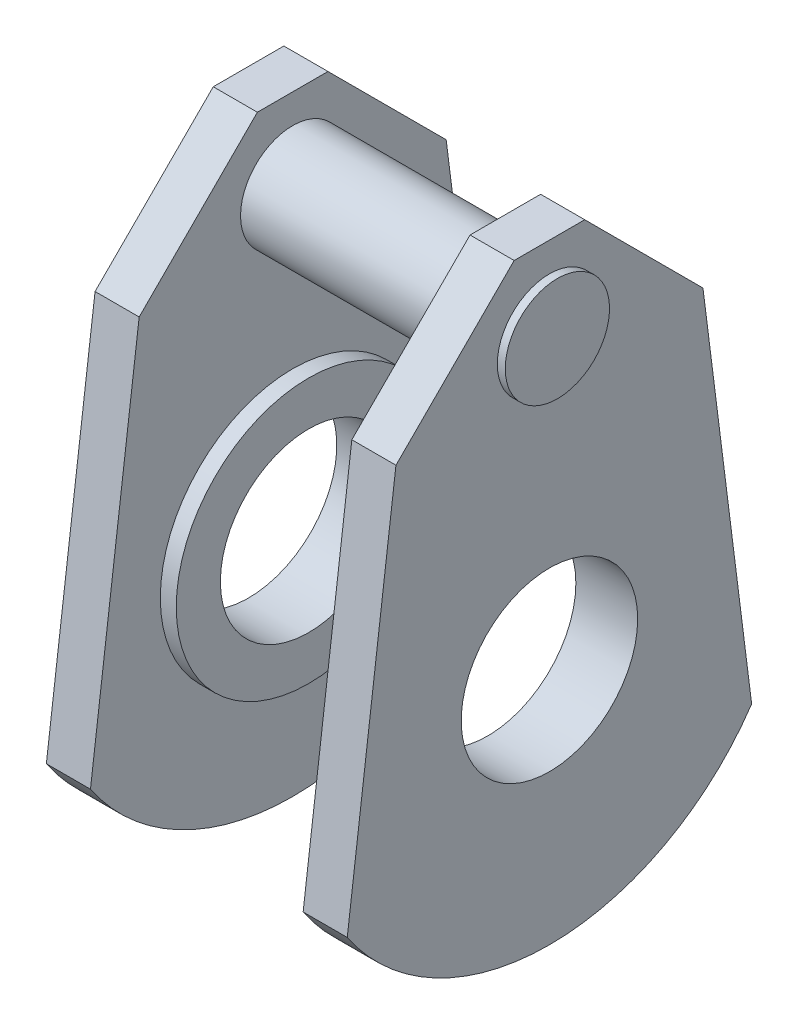
from build123d import *

# Parameters (mm, degrees)
IZIM2_R                          = 15
IZIM2_R_2                        = 10
Y_KSEKLIK_EKSTR_ZYON1_DEPTH      = 12.05
IZIM3_R                          = 10
Y_KSEKLIK_EKSTR_ZYON2_DEPTH      = 5
IZIM4_R                          = 15
Y_KSEKLIK_EKSTR_ZYON3_DEPTH      = 5
IZIM7_R                          = 15
IZIM7_R_2                        = 10
Y_KSEKLIK_EKSTR_ZYON4_DEPTH      = 5
IZIM5_R                          = 5.907014981
Y_KSEKLIK_EKSTR_ZYON5_DEPTH      = 1
Y_KSEKLIK_EKSTR_ZYON5_DEPTH_BACK = 35
SKETCH1_W                        = 20.286238667
SKETCH1_H                        = 40.774330455
CUT_EXTRUDE1_DEPTH               = 110


with BuildPart() as part:
    # Çizim2 → Yükseklik-Ekstrüzyon1 (new body, symmetric)
    with BuildSketch(Plane(origin=(0, 0, 0), x_dir=(0, 0, -1), z_dir=(1, 0, 0))):
        Circle(IZIM2_R)
        Circle(IZIM2_R_2, mode=Mode.SUBTRACT)
    extrude(amount=Y_KSEKLIK_EKSTR_ZYON1_DEPTH, both=True)

    # Çizim3 → Yükseklik-Ekstrüzyon2 (add)
    with BuildSketch(Plane(origin=(12.05, 0, 0), x_dir=(0, 0, -1), z_dir=(1, 0, 0))):
        with BuildLine():
            Line((-4, 42.176870951), (4, 42.176870951))
            Line((4, 42.176870951), (17.395555059, 28.781315891))
            Line((17.395555059, 28.781315891), (22.914530919, -14.80525669))
            ThreePointArc((22.914530919, -14.80525669), (0, -26.990652818), (-22.914530919, -14.80525669))
            Line((-22.914530919, -14.80525669), (-17.395555059, 28.781315891))
            Line((-17.395555059, 28.781315891), (-4, 42.176870951))
        make_face()
        Circle(IZIM3_R, mode=Mode.SUBTRACT)
    extrude(amount=Y_KSEKLIK_EKSTR_ZYON2_DEPTH)



with BuildPart() as body_2:
    # Çizim4 → Yükseklik-Ekstrüzyon3 (new body)
    with BuildSketch(Plane.ZY.offset(12.05)):
        with BuildLine():
            Line((-4, 42.176870951), (4, 42.176870951))
            Line((4, 42.176870951), (17.395555059, 28.781315891))
            Line((17.395555059, 28.781315891), (22.914530919, -14.80525669))
            ThreePointArc((22.914530919, -14.80525669), (0, -26.990652818), (-22.914530919, -14.80525669))
            Line((-22.914530919, -14.80525669), (-17.395555059, 28.781315891))
            Line((-17.395555059, 28.781315891), (-4, 42.176870951))
        make_face()
        Circle(IZIM4_R, mode=Mode.SUBTRACT)
    extrude(amount=Y_KSEKLIK_EKSTR_ZYON3_DEPTH)


with BuildPart() as part_1:
    add(part.part)

    add(body_2.part)  # Yükseklik-Ekstrüzyon4 merges body 2
    # Çizim7 → Yükseklik-Ekstrüzyon4 (add)
    with BuildSketch(Plane.ZY.offset(12.05)):
        Circle(IZIM7_R)
        Circle(IZIM7_R_2, mode=Mode.SUBTRACT)
    extrude(amount=Y_KSEKLIK_EKSTR_ZYON4_DEPTH)

    # Çizim5 → Yükseklik-Ekstrüzyon5 (add, two sides)
    with BuildSketch(Plane.ZY.offset(17.05)) as y_kseklik_ekstr_zyon5_sk:
        with Locations((0, 32.957419359)):
            Circle(IZIM5_R)
    extrude(amount=Y_KSEKLIK_EKSTR_ZYON5_DEPTH)
    extrude(y_kseklik_ekstr_zyon5_sk.sketch, amount=-Y_KSEKLIK_EKSTR_ZYON5_DEPTH_BACK)

    # Sketch1 → Cut-Extrude1 (cut)
    with BuildSketch(Plane.XY.offset(68.760639517)):
        with Locations((-0.100463281, -3.811592274)):
            Rectangle(SKETCH1_W, SKETCH1_H)
    extrude(amount=-CUT_EXTRUDE1_DEPTH, mode=Mode.SUBTRACT)


solid = part_1.part
